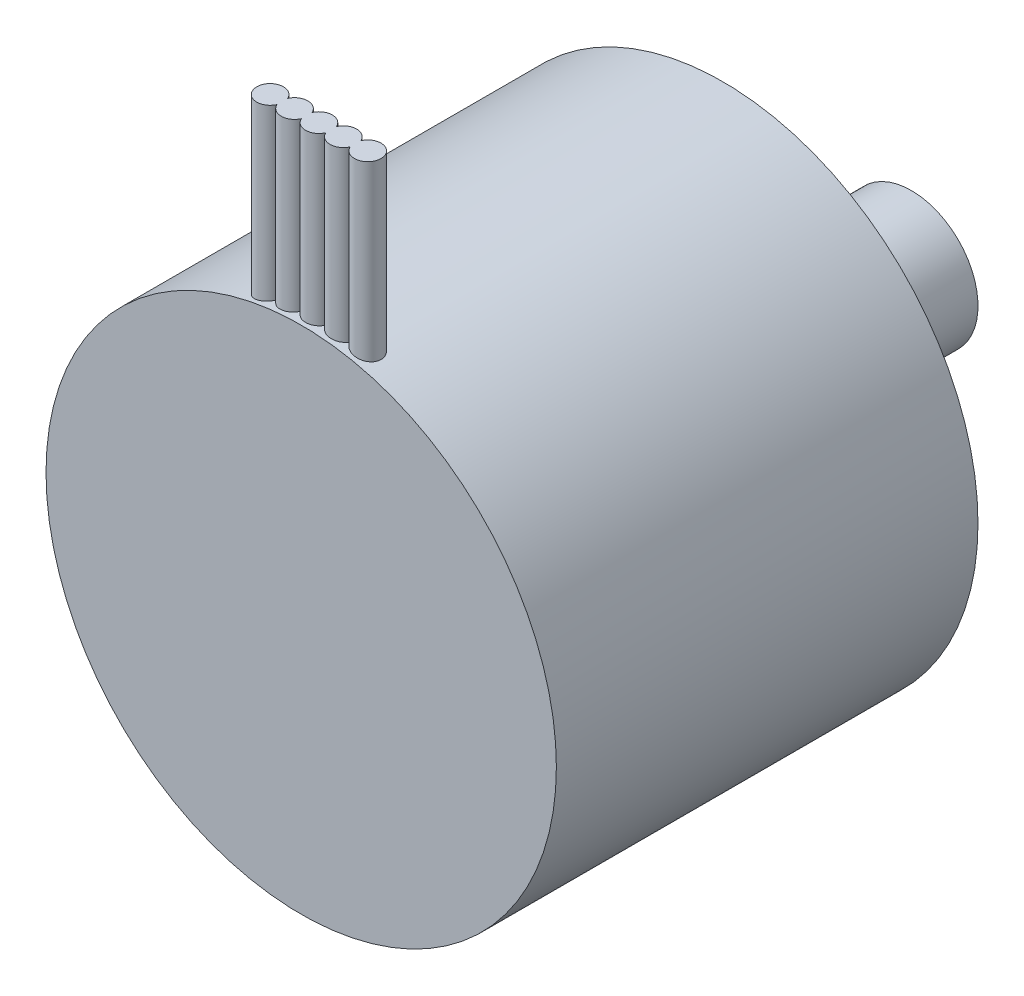
from build123d import *

# Parameters (mm, degrees)
SKETCH1_R           = 11.5
BOSS_EXTRUDE1_DEPTH = 19
SKETCH2_R           = 0.6
BOSS_EXTRUDE4_DEPTH = 19
SKETCH3_R           = 3
BOSS_EXTRUDE5_DEPTH = 8.5
SKETCH4_R           = 1
CUT_EXTRUDE1_DEPTH  = 8.5


with BuildPart() as part:
    # Sketch1 → Boss-Extrude1 (new body)
    with BuildSketch(Plane.XY):
        Circle(SKETCH1_R)
    extrude(amount=BOSS_EXTRUDE1_DEPTH)

    # Sketch2 → Boss-Extrude4 (add)
    with BuildSketch(Plane(origin=(0, 0, 0), x_dir=(1, 0, 0), z_dir=(0, 1, 0))):
        with Locations((-2.2, -18.2)):
            Circle(SKETCH2_R)
        with Locations((-1.1, -18.2)):
            Circle(SKETCH2_R)
        with Locations((0, -18.2)):
            Circle(SKETCH2_R)
        with Locations((1.1, -18.2)):
            Circle(SKETCH2_R)
        with Locations((2.2, -18.2)):
            Circle(SKETCH2_R)
    extrude(amount=BOSS_EXTRUDE4_DEPTH)

    # Sketch3 → Boss-Extrude5 (add)
    with BuildSketch(Plane(origin=(0, 0, 0), x_dir=(-1, 0, 0), z_dir=(0, 0, -1))):
        Circle(SKETCH3_R)
    extrude(amount=BOSS_EXTRUDE5_DEPTH)

    # Sketch4 → Cut-Extrude1 (cut)
    with BuildSketch(Plane(origin=(0, 0, 0), x_dir=(-1, 0, 0), z_dir=(0, 0, -1))):
        with Locations((0, -8.5)):
            Circle(SKETCH4_R)
        with Locations((0, 8.5)):
            Circle(SKETCH4_R)
    extrude(amount=-CUT_EXTRUDE1_DEPTH, mode=Mode.SUBTRACT)


solid = part.part
